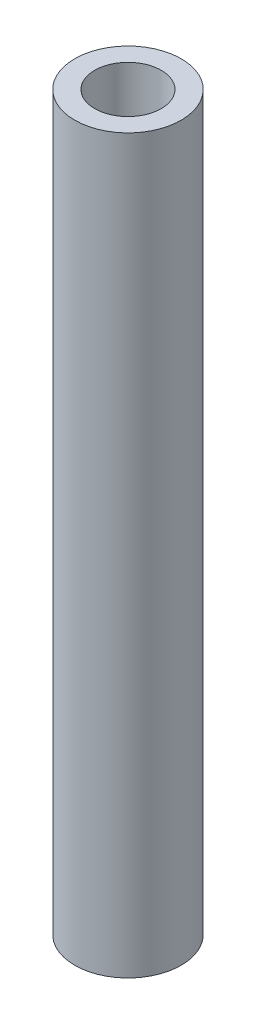
from build123d import *

# Parameters (mm, degrees)
SKETCH1_R           = 4
SKETCH1_R_2         = 2.5
BOSS_EXTRUDE1_DEPTH = 55


with BuildPart() as part:
    # Sketch1 → Boss-Extrude1 (new body)
    with BuildSketch(Plane(origin=(0, 0, 0), x_dir=(1, 0, 0), z_dir=(0, 1, 0))):
        Circle(SKETCH1_R)
        Circle(SKETCH1_R_2, mode=Mode.SUBTRACT)
    extrude(amount=BOSS_EXTRUDE1_DEPTH)


solid = part.part
